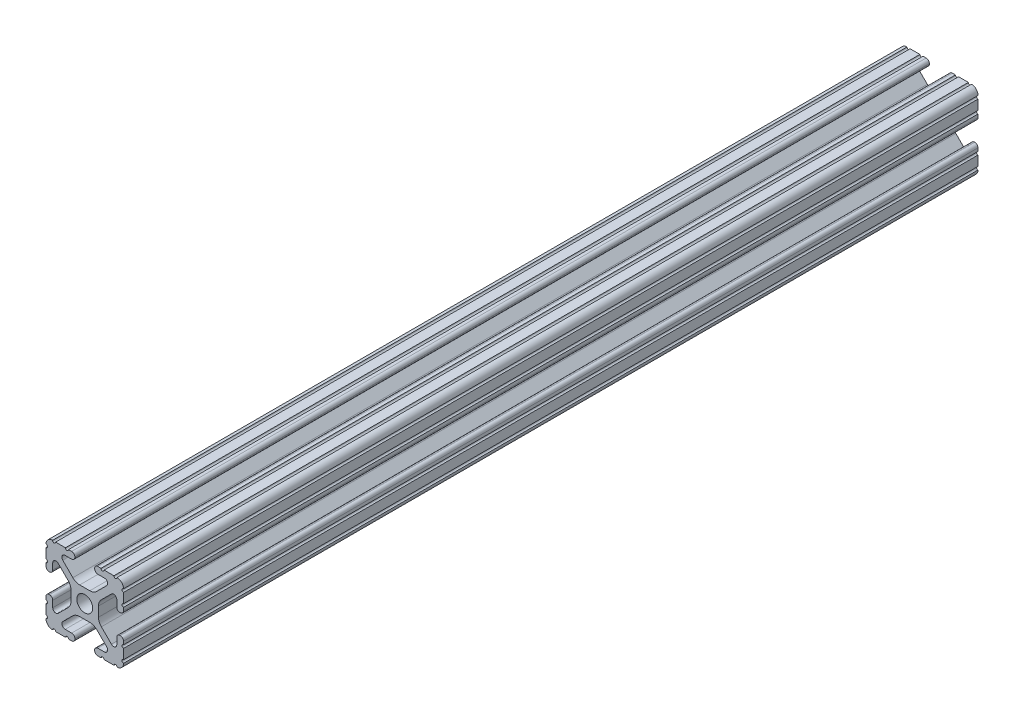
from build123d import *

# Parameters (mm, degrees)
SKETCH1_R           = 2.6035
BOSS_EXTRUDE1_DEPTH = 280


with BuildPart() as part:
    # Sketch1 → Boss-Extrude1 (new body)
    with BuildSketch(Plane.XY):
        with BuildLine():
            Line((-7.179650497, -8.645192506), (-3.952270251, -5.423690499))
            ThreePointArc((-3.952270251, -5.423690499), (-2.922936451, -4.736929036), (-1.709253557, -4.4958))
            Line((-1.709253557, -4.4958), (1.709253557, -4.4958))
            ThreePointArc((1.709253557, -4.4958), (2.922936451, -4.736929036), (3.952270251, -5.423690499))
            Line((3.952270251, -5.423690499), (7.179650497, -8.645192506))
            ThreePointArc((7.179650497, -8.645192506), (7.41473083, -9.822813117), (6.416408329, -10.4902))
            Line((6.416408329, -10.4902), (4.287512407, -10.4902))
            ThreePointArc((4.287512407, -10.4902), (3.54574862, -10.79744862), (3.2385, -11.539212407))
            Line((3.2385, -11.539212407), (3.2385, -11.650987593))
            ThreePointArc((3.2385, -11.650987593), (3.54574862, -12.39275138), (4.287512407, -12.7))
            Line((4.287512407, -12.7), (5.317126718, -12.7))
            ThreePointArc((5.317126718, -12.7), (5.825126718, -12.192), (6.333126718, -12.7))
            Line((6.333126718, -12.7), (9.550443118, -12.7))
            ThreePointArc((9.550443118, -12.7), (10.058366869, -12.192000006), (10.566443095, -12.699847501))
            ThreePointArc((10.566443095, -12.699847501), (12.082537762, -12.08250727), (12.699846982, -10.566399977))
            ThreePointArc((12.699846982, -10.566399977), (12.192000006, -10.058323491), (12.7, -9.5504))
            Line((12.7, -9.5504), (12.7, -6.3330836))
            ThreePointArc((12.7, -6.3330836), (12.192, -5.8250836), (12.7, -5.3170836))
            Line((12.7, -5.3170836), (12.7, -4.287469289))
            ThreePointArc((12.7, -4.287469289), (12.39275138, -3.545705502), (11.650987593, -3.238456882))
            Line((11.650987593, -3.238456882), (11.539212407, -3.238456882))
            ThreePointArc((11.539212407, -3.238456882), (10.79744862, -3.545705502), (10.4902, -4.287469289))
            Line((10.4902, -4.287469289), (10.4902, -6.402089023))
            ThreePointArc((10.4902, -6.402089023), (9.856505071, -7.351067942), (8.737131347, -7.129408934))
            Line((8.737131347, -7.129408934), (5.441005833, -3.840816462))
            ThreePointArc((5.441005833, -3.840816462), (4.750877967, -2.809883091), (4.5085, -1.593185507))
            Line((4.5085, -1.593185507), (4.5085, 1.593185507))
            ThreePointArc((4.5085, 1.593185507), (4.750877967, 2.809883091), (5.441005833, 3.840816462))
            Line((5.441005833, 3.840816462), (8.737131347, 7.129408934))
            ThreePointArc((8.737131347, 7.129408934), (9.856505071, 7.351067942), (10.4902, 6.402089023))
            Line((10.4902, 6.402089023), (10.4902, 4.287469289))
            ThreePointArc((10.4902, 4.287469289), (10.79744862, 3.545705502), (11.539212407, 3.238456882))
            Line((11.539212407, 3.238456882), (11.650987593, 3.238456882))
            ThreePointArc((11.650987593, 3.238456882), (12.39275138, 3.545705502), (12.7, 4.287469289))
            Line((12.7, 4.287469289), (12.7, 5.3170836))
            ThreePointArc((12.7, 5.3170836), (12.192, 5.8250836), (12.7, 6.3330836))
            Line((12.7, 6.3330836), (12.7, 9.5504))
            ThreePointArc((12.7, 9.5504), (12.192000006, 10.058323491), (12.699846982, 10.566399977))
            ThreePointArc((12.699846982, 10.566399977), (12.082537762, 12.08250727), (10.566443095, 12.699847501))
            ThreePointArc((10.566443095, 12.699847501), (10.058366869, 12.192000006), (9.550443118, 12.7))
            Line((9.550443118, 12.7), (6.333126718, 12.7))
            ThreePointArc((6.333126718, 12.7), (5.825126718, 12.192), (5.317126718, 12.7))
            Line((5.317126718, 12.7), (4.287512407, 12.7))
            ThreePointArc((4.287512407, 12.7), (3.54574862, 12.39275138), (3.2385, 11.650987593))
            Line((3.2385, 11.650987593), (3.2385, 11.539212407))
            ThreePointArc((3.2385, 11.539212407), (3.54574862, 10.79744862), (4.287512407, 10.4902))
            Line((4.287512407, 10.4902), (6.476788598, 10.4902))
            ThreePointArc((6.476788598, 10.4902), (7.432222385, 9.85140422), (7.207036008, 8.724370562))
            Line((7.207036008, 8.724370562), (3.898272566, 5.423169045))
            ThreePointArc((3.898272566, 5.423169045), (2.869120213, 4.736787962), (1.655778399, 4.4958))
            Line((1.655778399, 4.4958), (-1.655778399, 4.4958))
            ThreePointArc((-1.655778399, 4.4958), (-2.869120213, 4.736787962), (-3.898272566, 5.423169045))
            Line((-3.898272566, 5.423169045), (-7.207036008, 8.724370562))
            ThreePointArc((-7.207036008, 8.724370562), (-7.432222385, 9.85140422), (-6.476788598, 10.4902))
            Line((-6.476788598, 10.4902), (-4.287512407, 10.4902))
            ThreePointArc((-4.287512407, 10.4902), (-3.54574862, 10.79744862), (-3.2385, 11.539212407))
            Line((-3.2385, 11.539212407), (-3.2385, 11.650987593))
            ThreePointArc((-3.2385, 11.650987593), (-3.54574862, 12.39275138), (-4.287512407, 12.7))
            Line((-4.287512407, 12.7), (-5.317126718, 12.7))
            ThreePointArc((-5.317126718, 12.7), (-5.825126718, 12.192), (-6.333126718, 12.7))
            Line((-6.333126718, 12.7), (-9.550443118, 12.7))
            ThreePointArc((-9.550443118, 12.7), (-10.058366869, 12.192000006), (-10.566443095, 12.699847501))
            ThreePointArc((-10.566443095, 12.699847501), (-12.082537762, 12.08250727), (-12.699846982, 10.566399977))
            ThreePointArc((-12.699846982, 10.566399977), (-12.192000006, 10.058323491), (-12.7, 9.5504))
            Line((-12.7, 9.5504), (-12.7, 6.3330836))
            ThreePointArc((-12.7, 6.3330836), (-12.192, 5.8250836), (-12.7, 5.3170836))
            Line((-12.7, 5.3170836), (-12.7, 4.287469289))
            ThreePointArc((-12.7, 4.287469289), (-12.39275138, 3.545705502), (-11.650987593, 3.238456882))
            Line((-11.650987593, 3.238456882), (-11.539212407, 3.238456882))
            ThreePointArc((-11.539212407, 3.238456882), (-10.79744862, 3.545705502), (-10.4902, 4.287469289))
            Line((-10.4902, 4.287469289), (-10.4902, 6.402089023))
            ThreePointArc((-10.4902, 6.402089023), (-9.856505071, 7.351067942), (-8.737131347, 7.129408934))
            Line((-8.737131347, 7.129408934), (-5.441005833, 3.840816462))
            ThreePointArc((-5.441005833, 3.840816462), (-4.750877967, 2.809883091), (-4.5085, 1.593185507))
            Line((-4.5085, 1.593185507), (-4.5085, -1.593185507))
            ThreePointArc((-4.5085, -1.593185507), (-4.750877967, -2.809883091), (-5.441005833, -3.840816462))
            Line((-5.441005833, -3.840816462), (-8.737131347, -7.129408934))
            ThreePointArc((-8.737131347, -7.129408934), (-9.856505071, -7.351067942), (-10.4902, -6.402089023))
            Line((-10.4902, -6.402089023), (-10.4902, -4.287469289))
            ThreePointArc((-10.4902, -4.287469289), (-10.79744862, -3.545705502), (-11.539212407, -3.238456882))
            Line((-11.539212407, -3.238456882), (-11.650987593, -3.238456882))
            ThreePointArc((-11.650987593, -3.238456882), (-12.39275138, -3.545705502), (-12.7, -4.287469289))
            Line((-12.7, -4.287469289), (-12.7, -5.3170836))
            ThreePointArc((-12.7, -5.3170836), (-12.192, -5.8250836), (-12.7, -6.3330836))
            Line((-12.7, -6.3330836), (-12.7, -9.5504))
            ThreePointArc((-12.7, -9.5504), (-12.192000006, -10.058323491), (-12.699846982, -10.566399977))
            ThreePointArc((-12.699846982, -10.566399977), (-12.082537762, -12.08250727), (-10.566443095, -12.699847501))
            ThreePointArc((-10.566443095, -12.699847501), (-10.058366869, -12.192000006), (-9.550443118, -12.7))
            Line((-9.550443118, -12.7), (-6.333126718, -12.7))
            ThreePointArc((-6.333126718, -12.7), (-5.825126718, -12.192), (-5.317126718, -12.7))
            Line((-5.317126718, -12.7), (-4.287512407, -12.7))
            ThreePointArc((-4.287512407, -12.7), (-3.54574862, -12.39275138), (-3.2385, -11.650987593))
            Line((-3.2385, -11.650987593), (-3.2385, -11.539212407))
            ThreePointArc((-3.2385, -11.539212407), (-3.54574862, -10.79744862), (-4.287512407, -10.4902))
            Line((-4.287512407, -10.4902), (-6.416408329, -10.4902))
            ThreePointArc((-6.416408329, -10.4902), (-7.41473083, -9.822813117), (-7.179650497, -8.645192506))
        make_face()
        Circle(SKETCH1_R, mode=Mode.SUBTRACT)
    extrude(amount=BOSS_EXTRUDE1_DEPTH)


solid = part.part
